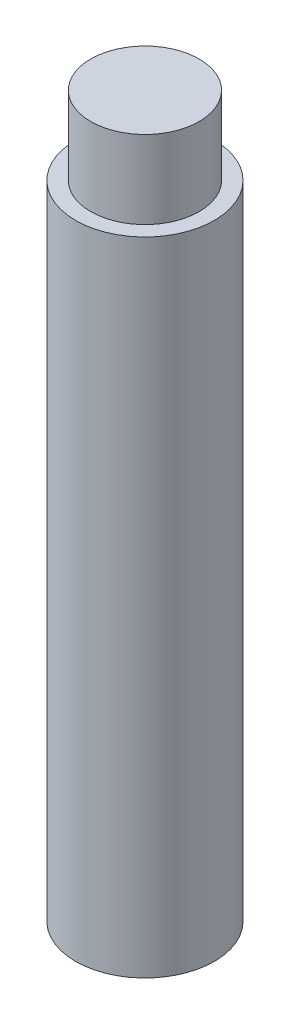
from build123d import *

# Parameters (mm, degrees)
SKETCH1_R           = 1.6
BOSS_EXTRUDE1_DEPTH = 7.4
SKETCH2_R           = 1.25
BOSS_EXTRUDE2_DEPTH = 1.8


with BuildPart() as part:
    # Sketch1 → Boss-Extrude1 (new body, symmetric)
    with BuildSketch(Plane(origin=(0, 0, 0), x_dir=(1, 0, 0), z_dir=(0, 1, 0))):
        Circle(SKETCH1_R)
    extrude(amount=BOSS_EXTRUDE1_DEPTH, both=True)

    # Sketch2 → Boss-Extrude2 (add)
    with BuildSketch(Plane(origin=(0, 7.4, 0), x_dir=(1, 0, 0), z_dir=(0, 1, 0))):
        Circle(SKETCH2_R)
    extrude(amount=BOSS_EXTRUDE2_DEPTH)


solid = part.part
